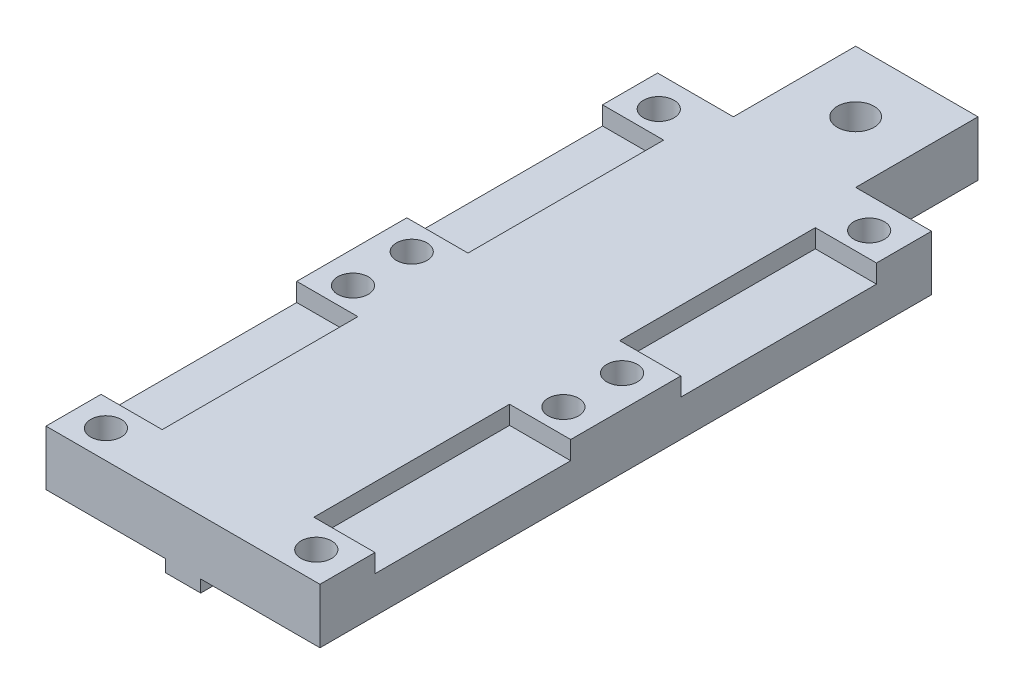
from build123d import *

# Parameters (mm, degrees)
BOSS_EXTRUDE1_DEPTH = 30
SKETCH3_R           = 1.5
SKETCH3_W           = 6.2
SKETCH3_H           = 10
MAKERBEAMFIX_DEPTH  = 6.5
SKETCH4_R           = 1.25
FIXHOLES_DEPTH      = 6.5
SKETCH5_W           = 5
SKETCH5_H           = 16
PINFIXHOLES_DEPTH   = 1.5
LPATTERN1_COUNT     = 2
LPATTERN1_PITCH     = 25


with BuildPart() as part:
    # Sketch1 → Boss-Extrude1 (new body, symmetric)
    with BuildSketch(Plane.XY):
        Polygon((-11.2, 1), (-1.45, 1), (-1.45, 0), (1.45, 0), (1.45, 1), (11.2, 1), (11.2, 5.5), (-11.2, 5.5), align=None)
    extrude(amount=BOSS_EXTRUDE1_DEPTH, both=True)

    # Sketch3 → MakerBeamFix (cut, through all)
    with BuildSketch(Plane(origin=(0, 5.5, 0), x_dir=(1, 0, 0), z_dir=(0, 1, 0))):
        with Locations((0, 25)):
            Circle(SKETCH3_R)
        with Locations((-8.1, 25)):
            Rectangle(SKETCH3_W, SKETCH3_H)
        with Locations((8.1, 25)):
            Rectangle(SKETCH3_W, SKETCH3_H)
    extrude(amount=-MAKERBEAMFIX_DEPTH, mode=Mode.SUBTRACT)

    # Sketch4 → FixHoles (cut, through all)
    with BuildSketch(Plane(origin=(0, 5.5, 0), x_dir=(1, 0, 0), z_dir=(0, 1, 0))):
        with Locations((-8.6, 17.5)):
            Circle(SKETCH4_R)
        with Locations((8.6, 17.5)):
            Circle(SKETCH4_R)
        with Locations((-8.6, -2.7)):
            Circle(SKETCH4_R)
        with Locations((8.6, -2.7)):
            Circle(SKETCH4_R)
    fixholes = extrude(amount=-FIXHOLES_DEPTH, mode=Mode.SUBTRACT)

    # Sketch5 → PinFixHoles (cut)
    with BuildSketch(Plane(origin=(0, 5.5, 0), x_dir=(1, 0, 0), z_dir=(0, 1, 0))):
        with Locations((-8.7, 7.5)):
            Rectangle(SKETCH5_W, SKETCH5_H)
        with Locations((8.7, 7.5)):
            Rectangle(SKETCH5_W, SKETCH5_H)
    pinfixholes = extrude(amount=-PINFIXHOLES_DEPTH, mode=Mode.SUBTRACT)

    # LPattern1: FixHoles, PinFixHoles ×2
    with Locations(*[(0, 0, i * LPATTERN1_PITCH) for i in range(1, LPATTERN1_COUNT)]):
        add(fixholes, mode=Mode.SUBTRACT)
        add(pinfixholes, mode=Mode.SUBTRACT)


solid = part.part
